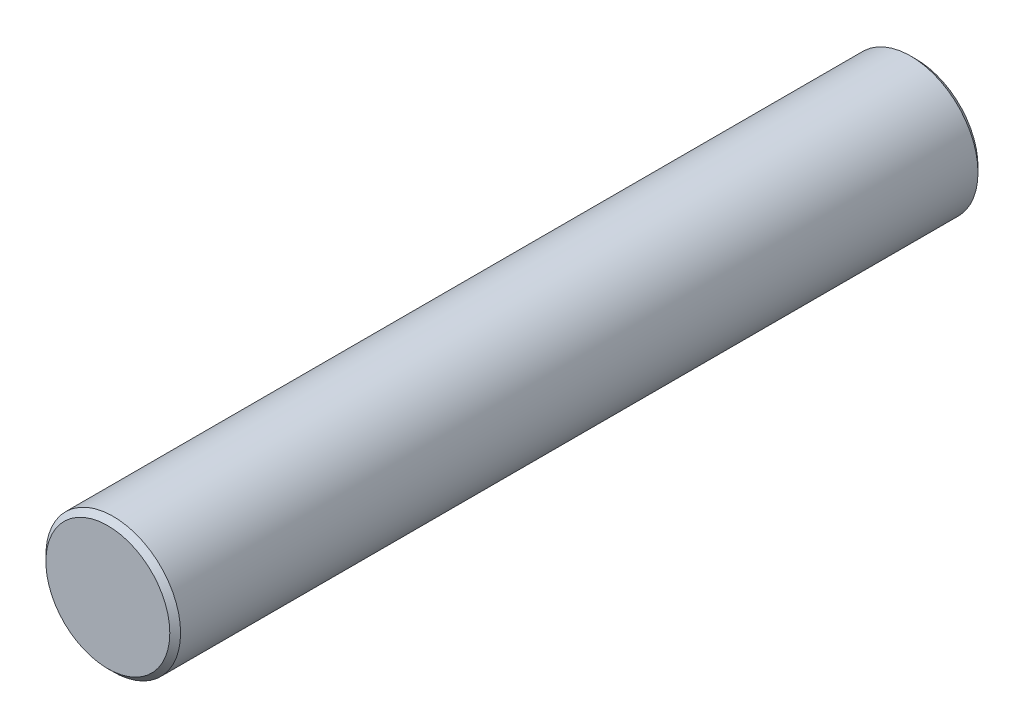
from build123d import *

# Parameters (mm, degrees)
SKETCH1_R           = 2.5
BOSS_EXTRUDE1_DEPTH = 30
CHAMFER1_SIZE       = 0.2


with BuildPart() as part:
    # Sketch1 → Boss-Extrude1 (new body)
    with BuildSketch(Plane.XY):
        Circle(SKETCH1_R)
    extrude(amount=BOSS_EXTRUDE1_DEPTH)

    # Chamfer1
    chamfer1_edges = [part.edges().sort_by_distance(p)[0] for p in [
        (-2.5, 0, 0),
        (-2.5, 0, 30),
    ]]
    chamfer(chamfer1_edges, length=CHAMFER1_SIZE)


solid = part.part
